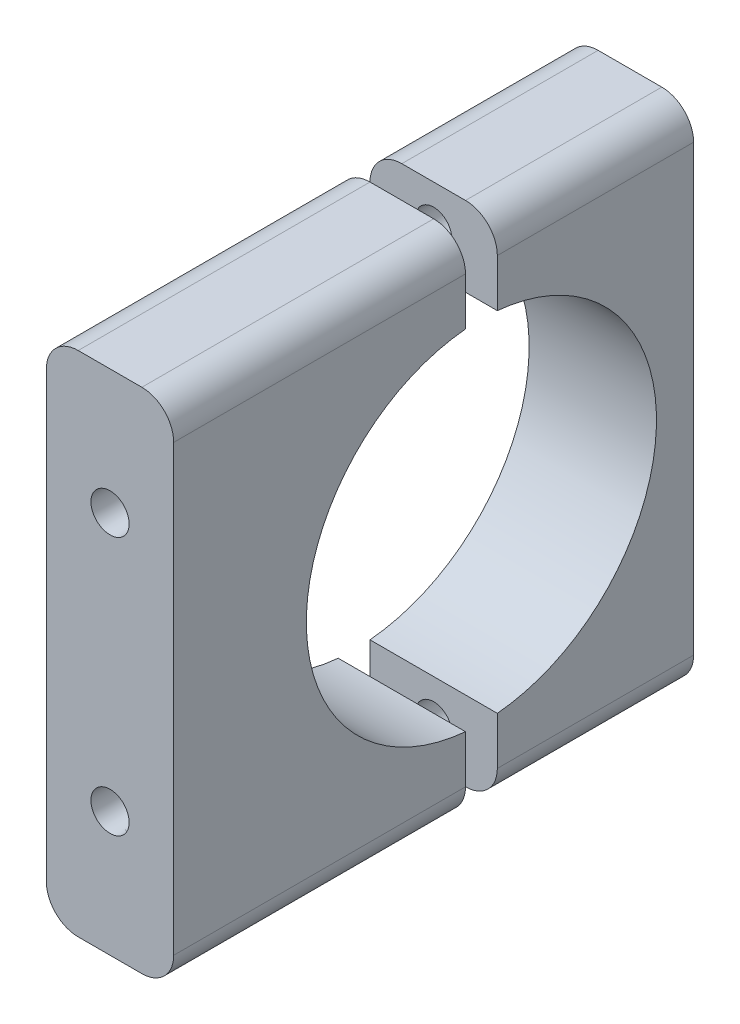
from build123d import *

# Parameters (mm, degrees)
BOSS_EXTRUDE1_DEPTH           = 12
BOSS_EXTRUDE1_2_DEPTH         = 12
FILLET1_R                     = 3
FILLET2_R                     = 3
CBORE_FOR_M3_SHCS1_AT_2_COUNT = 2
CBORE_FOR_M3_SHCS1_AT_2_PITCH = 40.36335345
SKETCH8_W                     = 1.8
SKETCH8_H                     = 6
HOLE1_AT_2_COUNT              = 2
HOLE1_AT_2_PITCH              = 40.36335345
SKETCH10_W                    = 1.8
SKETCH10_H                    = 4
HOLE2_AT_2_COUNT              = 2
HOLE2_AT_2_PITCH              = 24.36335345
SKETCH14_W                    = 1.8
SKETCH14_H                    = 6
HOLE3_AT_2_COUNT              = 2
HOLE3_AT_2_PITCH              = 24.36335345
DRAFT1_ANGLE                  = 2
DRAFT2_ANGLE                  = 2
DRAFT3_ANGLE                  = 2


with BuildPart() as part:
    # Sketch1 → Boss-Extrude1 (new body)
    with BuildSketch(Plane(origin=(0, 0, 0), x_dir=(0, 0, -1), z_dir=(1, 0, 0))):
        with BuildLine():
            Line((1.5, 23.931676725), (1.5, 16.431676725))
            ThreePointArc((1.5, 16.431676725), (12.186057607, 11.124297731), (16.5, 0))
            ThreePointArc((16.5, 0), (12.186057607, -11.124297731), (1.5, -16.431676725))
            Line((1.5, -16.431676725), (1.5, -23.931676725))
            Line((1.5, -23.931676725), (20, -23.931676725))
            Line((20, -23.931676725), (20, 23.931676725))
            Line((20, 23.931676725), (1.5, 23.931676725))
        make_face()
    extrude(amount=BOSS_EXTRUDE1_DEPTH)

    # Fillet1
    fillet1_edges = [part.edges().sort_by_distance(p)[0] for p in [
        (12, -23.931676725, -10.75),
        (12, 23.931676725, -10.75),
        (0, 23.931676725, -10.75),
        (0, -23.931676725, -10.75),
    ]]
    fillet(fillet1_edges, radius=FILLET1_R)

    # Sketch6 → CBORE for M3 SHCS1 (revolve, cut)
    with BuildSketch(Plane(origin=(6, 20.181676725, -20), x_dir=(0, 1, 0), z_dir=(1, 0, 0))):
        Polygon((0, 0), (0, 49), (1.7, 49), (1.7, 10), (3.25, 10), (3.25, 0.025), (3.275, 0), align=None)
    cbore_for_m3_shcs1 = revolve(axis=Axis((6, 20.181676725, -26.35), (0, 0, 1)), mode=Mode.SUBTRACT)

    # CBORE for M3 SHCS1 at 2: CBORE for M3 SHCS1 ×2
    with Locations(*[(0, -i * CBORE_FOR_M3_SHCS1_AT_2_PITCH, 0) for i in range(1, CBORE_FOR_M3_SHCS1_AT_2_COUNT)]):
        add(cbore_for_m3_shcs1, mode=Mode.SUBTRACT)

    # Sketch10 → Hole2 (revolve, cut)
    with BuildSketch(Plane(origin=(6, 12.181676725, -20), x_dir=(0, 1, 0), z_dir=(1, 0, 0))):
        with Locations((0.9, 2)):
            Rectangle(SKETCH10_W, SKETCH10_H)
    hole2 = revolve(axis=Axis((6, 12.181676725, 90), (0, 0, -1)), mode=Mode.SUBTRACT)

    # Hole2 at 2: Hole2 ×2
    with Locations(*[(0, -i * HOLE2_AT_2_PITCH, 0) for i in range(1, HOLE2_AT_2_COUNT)]):
        add(hole2, mode=Mode.SUBTRACT)

    # Draft1
    draft1_faces = [part.faces().sort_by_distance(p)[0] for p in [
        (6, -13.981676725, -18),
        (6, 10.381676725, -18),
    ]]
    draft(draft1_faces, Plane(origin=(12, 0, -20), x_dir=(-1, 0, 0), z_dir=(0, 0, -1)), DRAFT1_ANGLE)


with BuildPart() as body_2:
    # Sketch1 → Boss-Extrude1 2 (new body)
    with BuildSketch(Plane(origin=(0, 0, 0), x_dir=(0, 0, -1), z_dir=(1, 0, 0))):
        with BuildLine():
            ThreePointArc((-1.5, -16.431676725), (-16.5, 0), (-1.5, 16.431676725))
            Line((-1.5, 16.431676725), (-1.5, 23.931676725))
            Line((-1.5, 23.931676725), (-29, 23.931676725))
            Line((-29, 23.931676725), (-29, -23.931676725))
            Line((-29, -23.931676725), (-1.5, -23.931676725))
            Line((-1.5, -23.931676725), (-1.5, -16.431676725))
        make_face()
    extrude(amount=BOSS_EXTRUDE1_2_DEPTH)

    # Fillet2
    fillet2_edges = [body_2.edges().sort_by_distance(p)[0] for p in [
        (12, 23.931676725, 15.25),
        (12, -23.931676725, 15.25),
        (0, -23.931676725, 15.25),
        (0, 23.931676725, 15.25),
    ]]
    fillet(fillet2_edges, radius=FILLET2_R)

    # Sketch8 → Hole1 (revolve, cut)
    with BuildSketch(Plane(origin=(6, 20.181676725, 1.5), x_dir=(0, 1, 0), z_dir=(1, 0, 0))):
        with Locations((0.9, 3)):
            Rectangle(SKETCH8_W, SKETCH8_H)
    hole1 = revolve(axis=Axis((6, 20.181676725, 111.5), (0, 0, -1)), mode=Mode.SUBTRACT)

    # Hole1 at 2: Hole1 ×2
    with Locations(*[(0, -i * HOLE1_AT_2_PITCH, 0) for i in range(1, HOLE1_AT_2_COUNT)]):
        add(hole1, mode=Mode.SUBTRACT)

    # Sketch14 → Hole3 (revolve, cut)
    with BuildSketch(Plane(origin=(6, 12.181676725, 29), x_dir=(0, -1, 0), z_dir=(1, 0, 0))):
        with Locations((0.9, 3)):
            Rectangle(SKETCH14_W, SKETCH14_H)
    hole3 = revolve(axis=Axis((6, 12.181676725, -81), (0, 0, 1)), mode=Mode.SUBTRACT)

    # Hole3 at 2: Hole3 ×2
    with Locations(*[(0, -i * HOLE3_AT_2_PITCH, 0) for i in range(1, HOLE3_AT_2_COUNT)]):
        add(hole3, mode=Mode.SUBTRACT)

    # Draft2
    draft2_faces = [body_2.faces().sort_by_distance(p)[0] for p in [
        (6, -21.981676725, 4.5),
        (6, 18.381676725, 4.5),
    ]]
    draft(draft2_faces, Plane(origin=(12, 0, 1.5), x_dir=(0, -1, 0), z_dir=(0, 0, -1)), DRAFT2_ANGLE)

    # Draft3
    draft3_faces = [body_2.faces().sort_by_distance(p)[0] for p in [
        (6, -10.381676725, 26),
        (6, 13.981676725, 26),
    ]]
    draft(draft3_faces, Plane(origin=(12, 0, 29), x_dir=(1, 0, 0), z_dir=(0, 0, 1)), DRAFT3_ANGLE)


solid = Compound([part.part, body_2.part])
